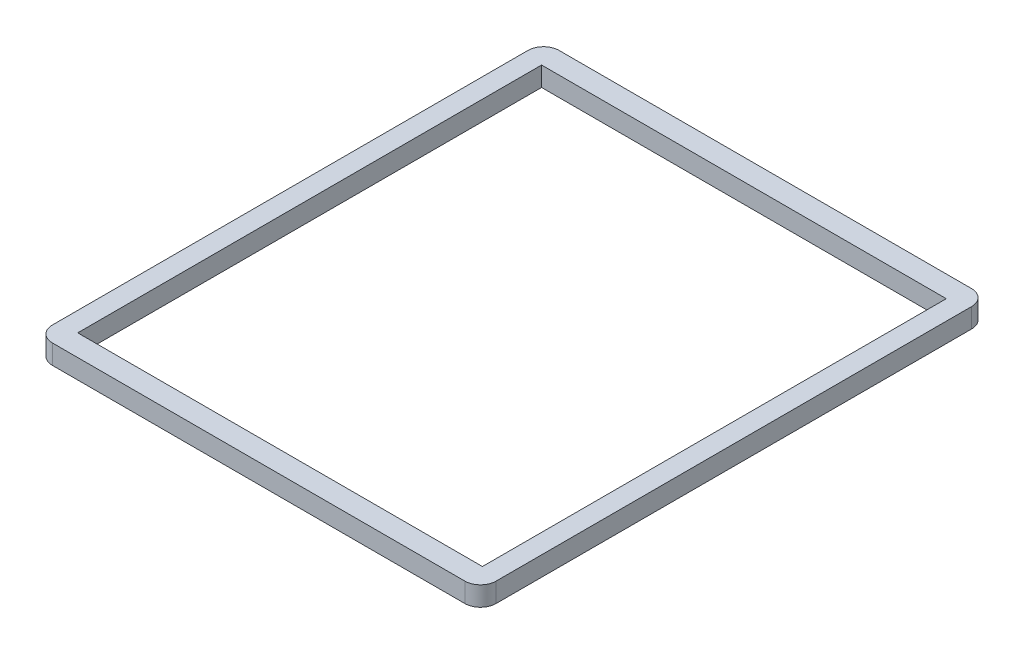
from build123d import *

# Parameters (mm, degrees)
SKETCH1_W           = 66.04
SKETCH1_H           = 75.692
BOSS_EXTRUDE2_DEPTH = 3.175


with BuildPart() as part:
    # Sketch1 → Boss-Extrude2 (new body)
    with BuildSketch(Plane(origin=(0, 0, 0), x_dir=(1, 0, 0), z_dir=(0, 1, 0))):
        with BuildLine():
            Line((2.54, 0), (69.85, 0))
            ThreePointArc((69.85, 0), (71.646051224, 0.743948776), (72.39, 2.54))
            Line((72.39, 2.54), (72.39, 80.137))
            ThreePointArc((72.39, 80.137), (71.646051224, 81.933051224), (69.85, 82.677))
            Line((69.85, 82.677), (2.54, 82.677))
            ThreePointArc((2.54, 82.677), (0.743948776, 81.933051224), (0, 80.137))
            Line((0, 80.137), (0, 2.54))
            ThreePointArc((0, 2.54), (0.743948776, 0.743948776), (2.54, 0))
        make_face()
        with Locations((36.195, 41.3385)):
            Rectangle(SKETCH1_W, SKETCH1_H, mode=Mode.SUBTRACT)
    extrude(amount=BOSS_EXTRUDE2_DEPTH)


solid = part.part
